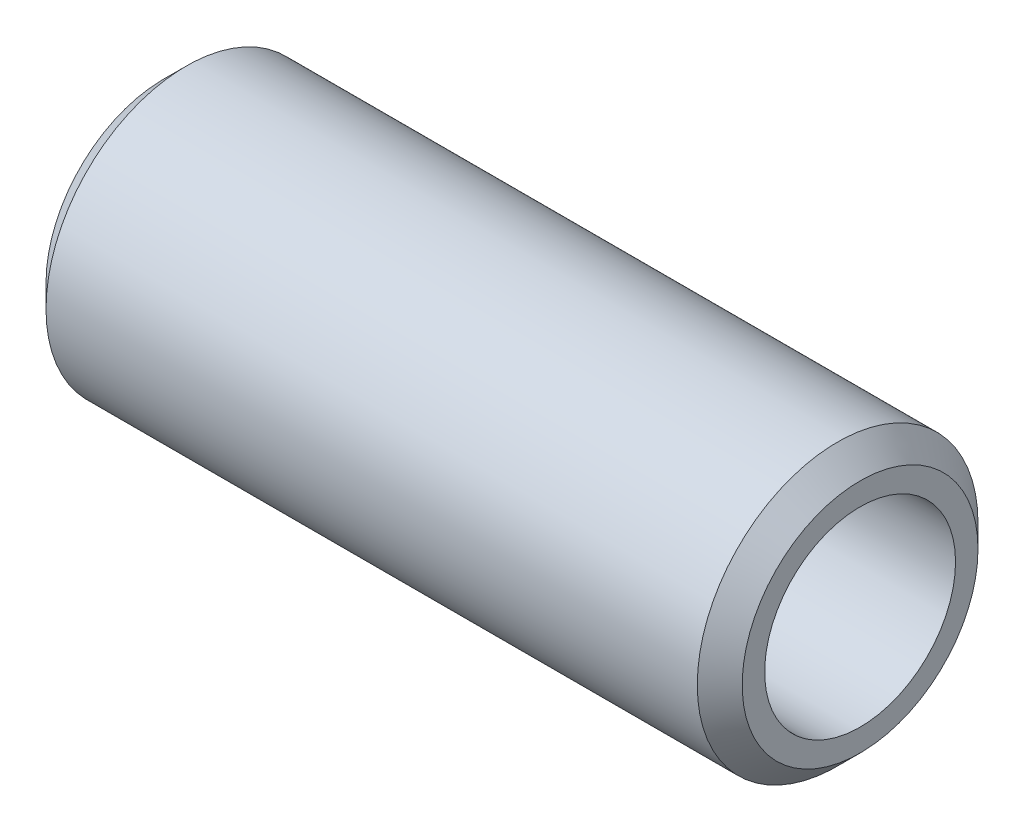
from build123d import *

# Parameters (mm, degrees)
SKETCH1_W          = 62
SKETCH1_H          = 12.5
SKETCH2_R          = 8.5
CUT_EXTRUDE1_DEPTH = 63
CHAMFER2_SIZE      = 2


with BuildPart() as part:
    # Sketch1 → Revolve1 (revolve)
    with BuildSketch(Plane.XY):
        with Locations((0, 6.25)):
            Rectangle(SKETCH1_W, SKETCH1_H)
    revolve(axis=Axis((31, 0, 0), (-1, 0, 0)))

    # Sketch2 → Cut-Extrude1 (cut, through all)
    with BuildSketch(Plane(origin=(31, 0, 0), x_dir=(0, 0, -1), z_dir=(1, 0, 0))):
        Circle(SKETCH2_R)
    extrude(amount=-CUT_EXTRUDE1_DEPTH, mode=Mode.SUBTRACT)

    # Chamfer2
    chamfer2_edges = [part.edges().sort_by_distance(p)[0] for p in [
        (31, -12.5, 0),
        (-31, -12.5, 0),
    ]]
    chamfer(chamfer2_edges, length=CHAMFER2_SIZE)


solid = part.part
